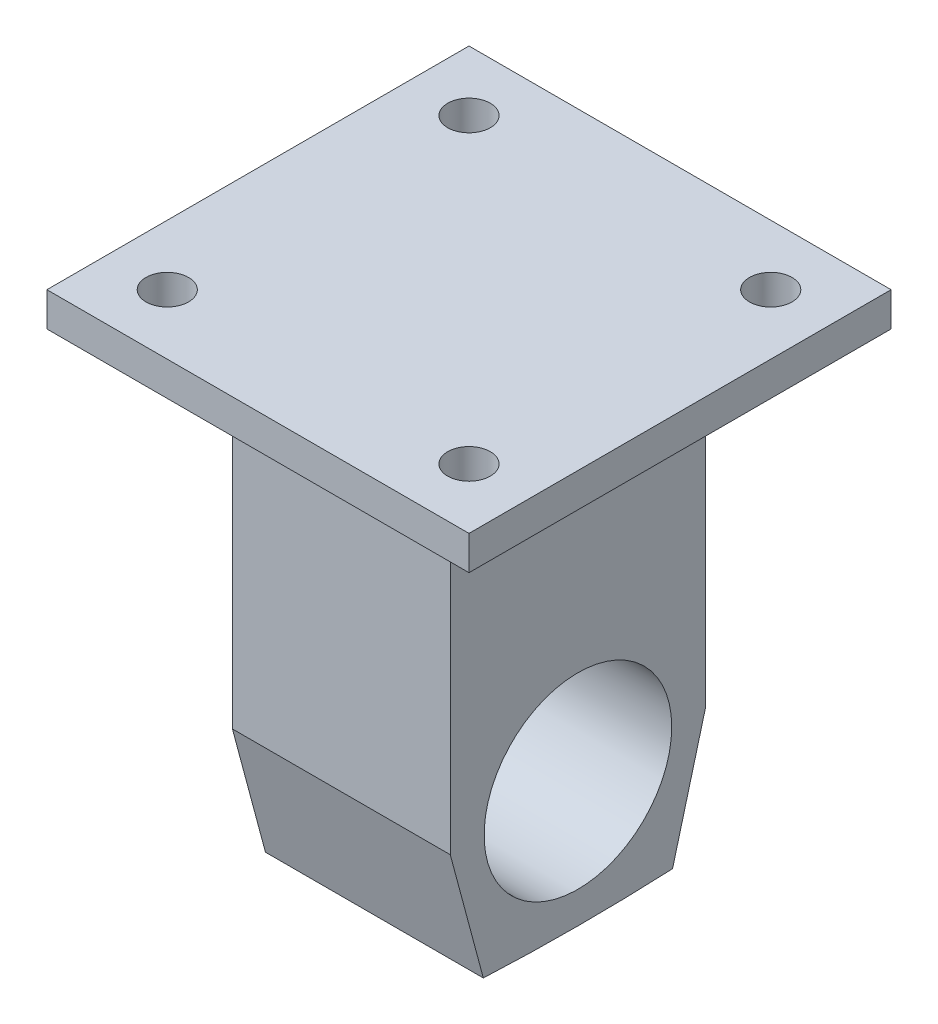
from build123d import *

# Parameters (mm, degrees)
SKETCH1_W           = 32.512
SKETCH1_H           = 38.1
BOSS_EXTRUDE1_DEPTH = 50.292
BOSS_EXTRUDE2_DEPTH = 32.512
SKETCH3_R           = 14
CUT_EXTRUDE1_DEPTH  = 127
SKETCH4_W           = 62.992
SKETCH4_H           = 62.992
BOSS_EXTRUDE3_DEPTH = 5.08
SKETCH5_R           = 3.175
CUT_EXTRUDE2_DEPTH  = 75.105351542


with BuildPart() as part:
    # Sketch1 → Boss-Extrude1 (new body)
    with BuildSketch(Plane(origin=(0, 0, 0), x_dir=(1, 0, 0), z_dir=(0, 1, 0))):
        Rectangle(SKETCH1_W, SKETCH1_H)
    extrude(amount=BOSS_EXTRUDE1_DEPTH)

    # Sketch2 → Boss-Extrude2 (add)
    with BuildSketch(Plane(origin=(16.256, 0, 0), x_dir=(0, 0, -1), z_dir=(1, 0, 0))):
        with BuildLine():
            Line((-19.05, 0), (-14.119497191, -18.400886991))
            ThreePointArc((-14.119497191, -18.400886991), (0, -18.733351542), (14.119497191, -18.400886991))
            Line((14.119497191, -18.400886991), (19.05, 0))
            Line((19.05, 0), (-19.05, 0))
        make_face()
    extrude(amount=-BOSS_EXTRUDE2_DEPTH)

    # Sketch3 → Cut-Extrude1 (cut)
    with BuildSketch(Plane(origin=(16.256, 0, 0), x_dir=(0, 0, -1), z_dir=(1, 0, 0))):
        Circle(SKETCH3_R)
    extrude(amount=-CUT_EXTRUDE1_DEPTH, mode=Mode.SUBTRACT)

    # Sketch4 → Boss-Extrude3 (add)
    with BuildSketch(Plane(origin=(0, 50.292, 0), x_dir=(1, 0, 0), z_dir=(0, 1, 0))):
        Rectangle(SKETCH4_W, SKETCH4_H)
    extrude(amount=BOSS_EXTRUDE3_DEPTH)

    # Sketch5 → Cut-Extrude2 (cut, through all)
    with BuildSketch(Plane(origin=(0, 55.372, 0), x_dir=(1, 0, 0), z_dir=(0, 1, 0))):
        with Locations((-22.515743879, 22.515743879)):
            Circle(SKETCH5_R)
        with Locations((22.515743879, 22.515743879)):
            Circle(SKETCH5_R)
        with Locations((-22.515743879, -22.515743879)):
            Circle(SKETCH5_R)
        with Locations((22.515743879, -22.515743879)):
            Circle(SKETCH5_R)
    extrude(amount=-CUT_EXTRUDE2_DEPTH, mode=Mode.SUBTRACT)


solid = part.part
